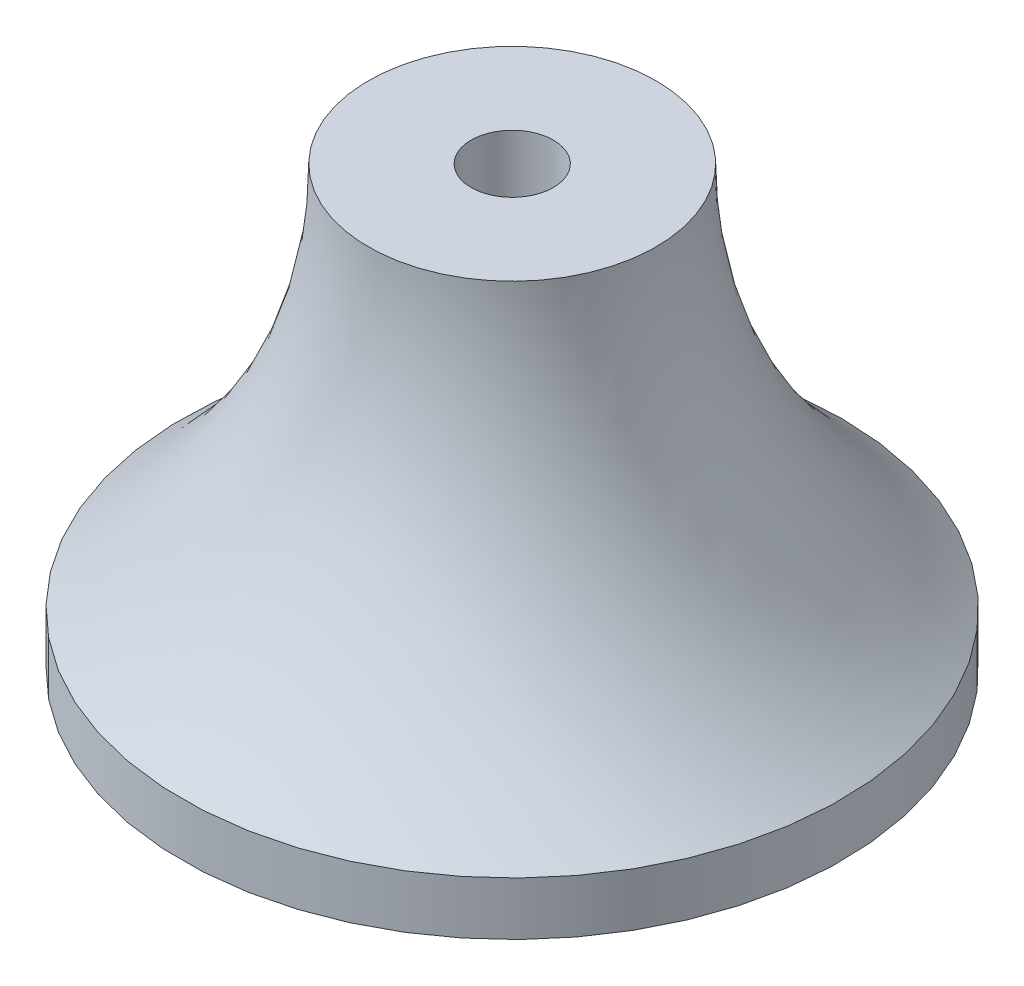
from build123d import *

# Parameters (mm, degrees)
CUT_EXTRUDE1_DEPTH = 16.096219


with BuildPart() as part:
    # Sketch2 → Revolve1 (revolve)
    with BuildSketch(Plane.XY):
        with BuildLine():
            Line((2.032, -2.634219297), (2.032, 19.05))
            Line((2.032, 19.05), (7.112, 19.05))
            ThreePointArc((7.112, 19.05), (9.527739154, 8.475956955), (16.295629201, 0))
            Line((16.295629201, 0), (16.295629201, -2.634219297))
            Line((16.295629201, -2.634219297), (2.032, -2.634219297))
        make_face()
    revolve(axis=Axis((0, 0, 0), (0, 1, 0)))

    # Sketch3 → Cut-Extrude1 (cut)
    with BuildSketch(Plane.XZ.offset(2.634219297)):
        Polygon((4.80775348, 0.552100056), (1.925744066, 4.439686677), (-2.882009414, 3.887586621), (-4.80775348, -0.552100056), (-1.925744066, -4.439686677), (2.882009414, -3.887586621), align=None)
    extrude(amount=-CUT_EXTRUDE1_DEPTH, mode=Mode.SUBTRACT)


solid = part.part
